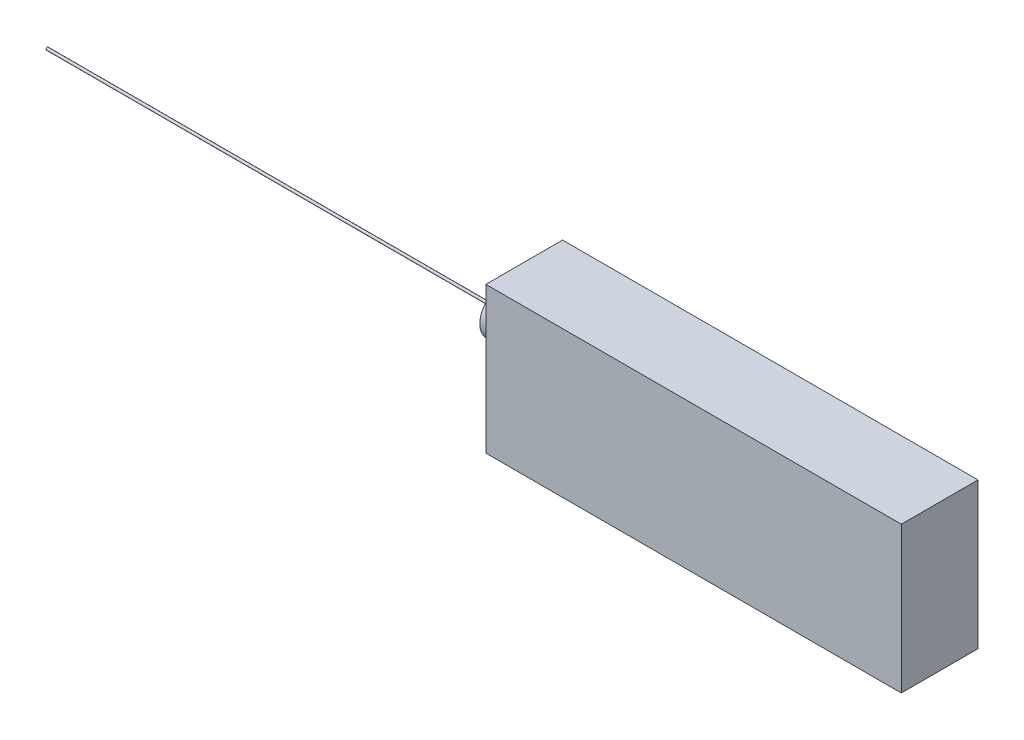
from build123d import *

# Parameters (mm, degrees)
SKETCH1_W           = 325
SKETCH1_H           = 60
BOSS_EXTRUDE1_DEPTH = 114.37
SKETCH2_R           = 17.238668945
BOSS_EXTRUDE2_DEPTH = 25
SKETCH3_R           = 1
BOSS_EXTRUDE3_DEPTH = 355.6


with BuildPart() as part:
    # Sketch1 → Boss-Extrude1 (new body)
    with BuildSketch(Plane(origin=(0, 0, 0), x_dir=(1, 0, 0), z_dir=(0, 1, 0))):
        Rectangle(SKETCH1_W, SKETCH1_H)
    extrude(amount=-BOSS_EXTRUDE1_DEPTH)

    # Sketch2 → Boss-Extrude2 (add)
    with BuildSketch(Plane.ZY.offset(162.5)):
        with Locations((-7.5, -49.37)):
            Circle(SKETCH2_R)
    extrude(amount=BOSS_EXTRUDE2_DEPTH)

    # Sketch3 → Boss-Extrude3 (add)
    with BuildSketch(Plane.ZY.offset(187.5)):
        with Locations((-7.5, -49.37)):
            Circle(SKETCH3_R)
    extrude(amount=BOSS_EXTRUDE3_DEPTH)


solid = part.part
